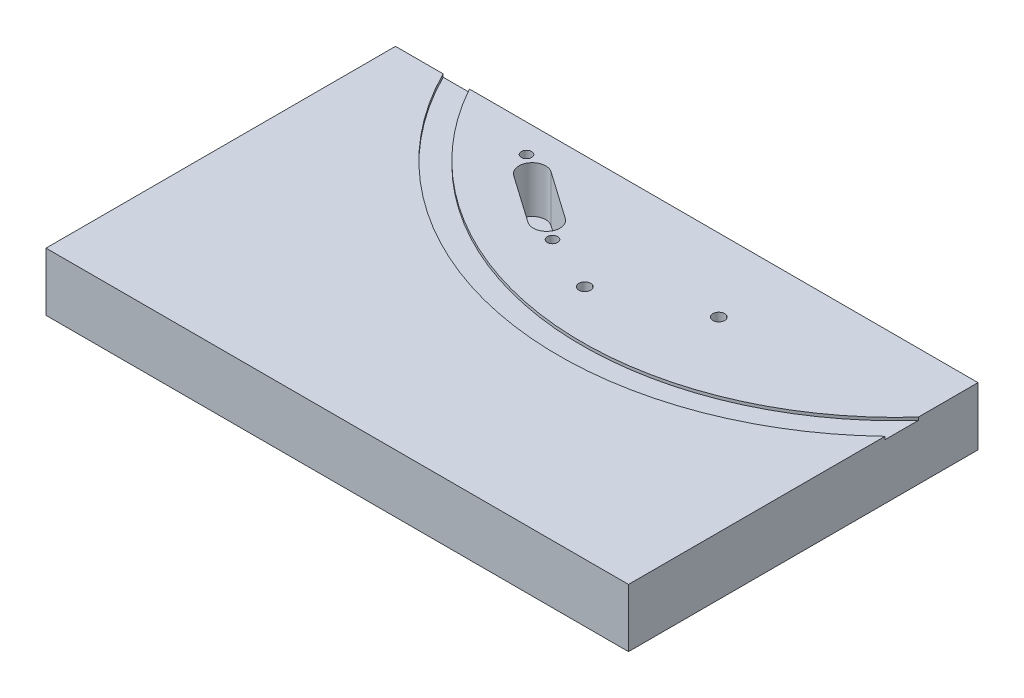
from build123d import *

# Parameters (mm, degrees)
SKETCH1_W                    = 100
SKETCH1_H                    = 60
BOSS_EXTRUDE1_DEPTH          = 10
M2_5X0_45_TAPPED_HOLE1_D     = 2.05
M2_5X0_45_TAPPED_HOLE1_DEPTH = 6.35
M2_5X0_45_TAPPED_HOLE1_TIP   = 0.615882135
F_2_56_TAPPED_HOLE1_D        = 1.778
F_2_56_TAPPED_HOLE1_DEPTH    = 5.73
F_2_56_TAPPED_HOLE1_TIP      = 0.53416509
CUT_EXTRUDE2_DEPTH           = 8
M3X0_5_TAPPED_HOLE2_D        = 2.5
M3X0_5_TAPPED_HOLE2_DEPTH    = 7.5
M3X0_5_TAPPED_HOLE2_TIP      = 0.751075774
CUT_EXTRUDE3_DEPTH           = 0.5


with BuildPart() as part:
    # Sketch1 → Boss-Extrude1 (new body)
    with BuildSketch(Plane(origin=(0, 0, 0), x_dir=(1, 0, 0), z_dir=(0, 1, 0))):
        with Locations((50, -30)):
            Rectangle(SKETCH1_W, SKETCH1_H)
    extrude(amount=BOSS_EXTRUDE1_DEPTH)

    # M2.5x0.45 Tapped Hole1
    with Locations(Plane(origin=(0, 10, 0), x_dir=(1, 0, 0), z_dir=(0, 1, 0))):
        with Locations((52, -19.5), (68, -12.5)):
            Hole(M2_5X0_45_TAPPED_HOLE1_D / 2, depth=M2_5X0_45_TAPPED_HOLE1_DEPTH)
            with Locations((0, 0, -(M2_5X0_45_TAPPED_HOLE1_DEPTH + M2_5X0_45_TAPPED_HOLE1_TIP / 2))):  # 118° drill point
                Cone(0, M2_5X0_45_TAPPED_HOLE1_D / 2, M2_5X0_45_TAPPED_HOLE1_TIP, mode=Mode.SUBTRACT)

    # 2-56 Tapped Hole1
    with Locations(Plane(origin=(0, 10, 0), x_dir=(1, 0, 0), z_dir=(0, 1, 0))):
        with Locations((42.200946939, -15.251050779), (27.324326662, -4.834329118)):
            Hole(F_2_56_TAPPED_HOLE1_D / 2, depth=F_2_56_TAPPED_HOLE1_DEPTH)
            with Locations((0, 0, -(F_2_56_TAPPED_HOLE1_DEPTH + F_2_56_TAPPED_HOLE1_TIP / 2))):  # 118° drill point
                Cone(0, F_2_56_TAPPED_HOLE1_D / 2, F_2_56_TAPPED_HOLE1_TIP, mode=Mode.SUBTRACT)

    # Sketch6 → Cut-Extrude2 (cut)
    with BuildSketch(Plane(origin=(0, 10, 0), x_dir=(1, 0, 0), z_dir=(0, 1, 0))):
        with BuildLine():
            Line((37.539171218, -14.794621832), (29.347650776, -9.058857469))
            ThreePointArc((29.347650776, -9.058857469), (28.782826877, -5.855581963), (31.986102383, -5.290758065))
            Line((31.986102383, -5.290758065), (40.177622826, -11.026522429))
            ThreePointArc((40.177622826, -11.026522429), (40.742446724, -14.229797934), (37.539171218, -14.794621832))
        make_face()
    extrude(amount=-CUT_EXTRUDE2_DEPTH, mode=Mode.SUBTRACT)

    # M3x0.5 Tapped Hole2
    with Locations(Plane(origin=(0, 0, 0), x_dir=(-1, 0, 0), z_dir=(0, 0, -1))):
        with Locations((-20, 5), (-70, 5)):
            Hole(M3X0_5_TAPPED_HOLE2_D / 2, depth=M3X0_5_TAPPED_HOLE2_DEPTH)
            with Locations((0, 0, -(M3X0_5_TAPPED_HOLE2_DEPTH + M3X0_5_TAPPED_HOLE2_TIP / 2))):  # 118° drill point
                Cone(0, M3X0_5_TAPPED_HOLE2_D / 2, M3X0_5_TAPPED_HOLE2_TIP, mode=Mode.SUBTRACT)

    # Sketch12 → Cut-Extrude3 (cut)
    with BuildSketch(Plane(origin=(0, 10, 0), x_dir=(1, 0, 0), z_dir=(0, 1, 0))):
        with BuildLine():
            ThreePointArc((100, -10.239489856), (52.707108631, -27.480037028), (11.757236622, 1.793876671))
            ThreePointArc((11.757236622, 1.793876671), (9.072701681, 2.684534941), (8.182043412, 0))
            ThreePointArc((8.182043412, 0), (52.166644241, -31.443356122), (102.96433534, -12.925139868))
            ThreePointArc((102.96433534, -12.925139868), (102.824992676, -10.100147192), (100, -10.239489856))
        make_face()
    extrude(amount=-CUT_EXTRUDE3_DEPTH, mode=Mode.SUBTRACT)


solid = part.part
